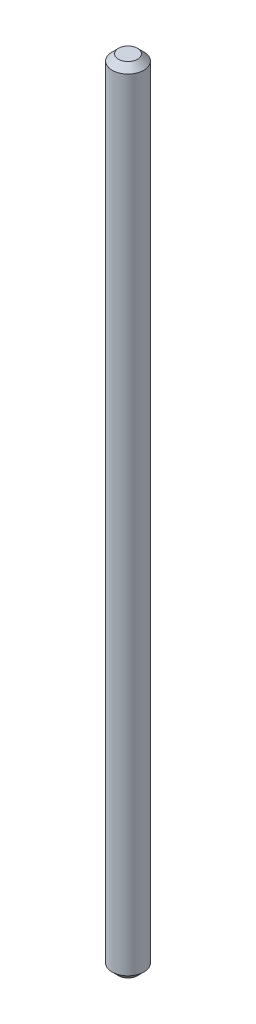
from build123d import *

# Parameters (mm, degrees)
SKETCH1_R           = 5
BOSS_EXTRUDE1_DEPTH = 250
CHAMFER1_SIZE       = 2


with BuildPart() as part:
    # Sketch1 → Boss-Extrude1 (new body)
    with BuildSketch(Plane(origin=(0, 0, 0), x_dir=(1, 0, 0), z_dir=(0, 1, 0))):
        with Locations(Location((0, 0, 0), (0, 0, 270))):  # turned: the seam where the file's is
            Circle(SKETCH1_R)
    extrude(amount=BOSS_EXTRUDE1_DEPTH)

    # Chamfer1
    chamfer1_edges = [part.edges().sort_by_distance(p)[0] for p in [
        (0, 0, -5),
        (0, 250, -5),
    ]]
    chamfer(chamfer1_edges, length=CHAMFER1_SIZE)


solid = part.part
